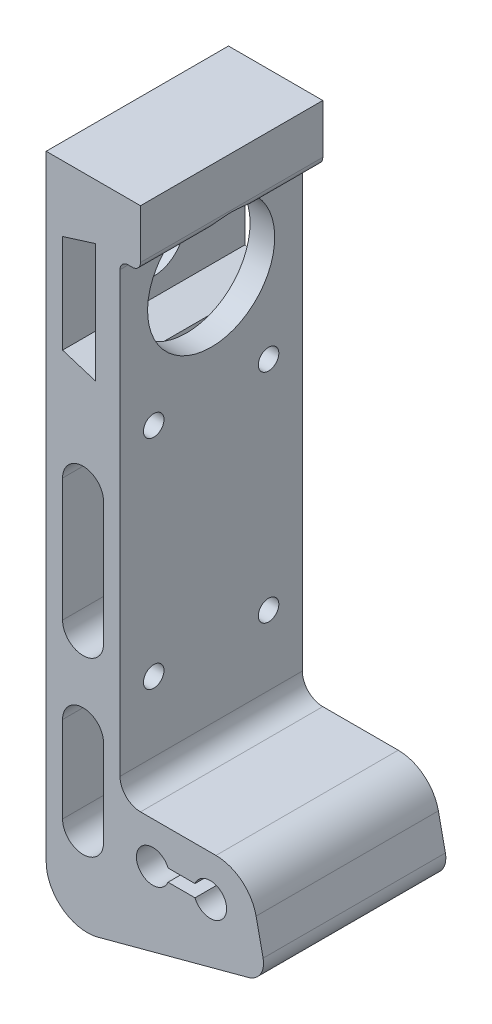
from build123d import *

# Parameters (mm, degrees)
BOSS_EXTRUDE1_DEPTH = 22.225
SKETCH2_R           = 2.5
SKETCH2_R_2         = 7.5
CUT_EXTRUDE5_DEPTH  = 18
CUT_EXTRUDE7_START  = 12
SKETCH2_8_R         = 15.5
CUT_EXTRUDE7_DEPTH  = 42


with BuildPart() as part:
    # Sketch1 → Boss-Extrude1 (new body, symmetric)
    with BuildSketch(Plane.XY):
        with BuildLine():
            Line((0, 28), (0, -122))
            ThreePointArc((0, -122), (3.91238571, -129.933533403), (12.588190451, -131.659258263))
            Line((12.588190451, -131.659258263), (49.294095226, -121.823940721))
            ThreePointArc((49.294095226, -121.823940721), (52.263200822, -119.606804413), (52.890738004, -115.954753136))
            Line((52.890738004, -115.954753136), (51.18308621, -107.920883092))
            ThreePointArc((51.18308621, -107.920883092), (47.694814113, -102.228540385), (41.401610203, -100))
            Line((41.401610203, -100), (23, -100))
            ThreePointArc((23, -100), (19.464466094, -98.535533906), (18, -95))
            Line((18, -95), (18, 12))
            ThreePointArc((18, 12), (18.585786438, 13.414213562), (20, 14))
            Line((20, 14), (21, 14))
            ThreePointArc((21, 14), (22.414213562, 14.585786438), (23, 16))
            Line((23, 16), (23, 28))
            Line((23, 28), (18, 28))
            Line((18, 28), (0, 28))
        make_face()
        with BuildLine():
            Line((4, -111), (4, -90))
            ThreePointArc((4, -90), (9, -85), (14, -90))
            Line((14, -90), (14, -111))
            ThreePointArc((14, -111), (9, -116), (4, -111))
        make_face(mode=Mode.SUBTRACT)
        with BuildLine():
            Line((4, -69), (4, -39))
            ThreePointArc((4, -39), (9, -34), (14, -39))
            Line((14, -39), (14, -69))
            ThreePointArc((14, -69), (9, -74), (4, -69))
        make_face(mode=Mode.SUBTRACT)
        with BuildLine():
            Line((29.708099244, -108.5), (36.291900756, -108.5))
            ThreePointArc((36.291900756, -108.5), (44, -110), (36.291900756, -111.5))
            Line((36.291900756, -111.5), (29.708099244, -111.5))
            ThreePointArc((29.708099244, -111.5), (22, -110), (29.708099244, -108.5))
        make_face(mode=Mode.SUBTRACT)
        Polygon((4, 12), (4, -12), (12, -14.5), (12, 14.5), align=None, mode=Mode.SUBTRACT)
    extrude(amount=BOSS_EXTRUDE1_DEPTH, both=True)

    # Sketch2 → Cut-Extrude5 (cut)
    with BuildSketch(Plane(origin=(0, 0, 0), x_dir=(0, 0, -1), z_dir=(1, 0, 0))):
        with Locations((14, -78)):
            Circle(SKETCH2_R)
        with Locations((-14, -78)):
            Circle(SKETCH2_R)
        with Locations((-14, -25)):
            Circle(SKETCH2_R)
        with Locations((14, -25)):
            Circle(SKETCH2_R)
        Circle(SKETCH2_R_2)
    extrude(amount=CUT_EXTRUDE5_DEPTH, mode=Mode.SUBTRACT)

    # Sketch2_8 → Cut-Extrude7 (cut, through all)
    with BuildSketch(Plane(origin=(0, 0, 0), x_dir=(0, 0, -1), z_dir=(1, 0, 0)).offset(CUT_EXTRUDE7_START)):
        Circle(SKETCH2_8_R)
    extrude(amount=CUT_EXTRUDE7_DEPTH, mode=Mode.SUBTRACT)


solid = part.part
